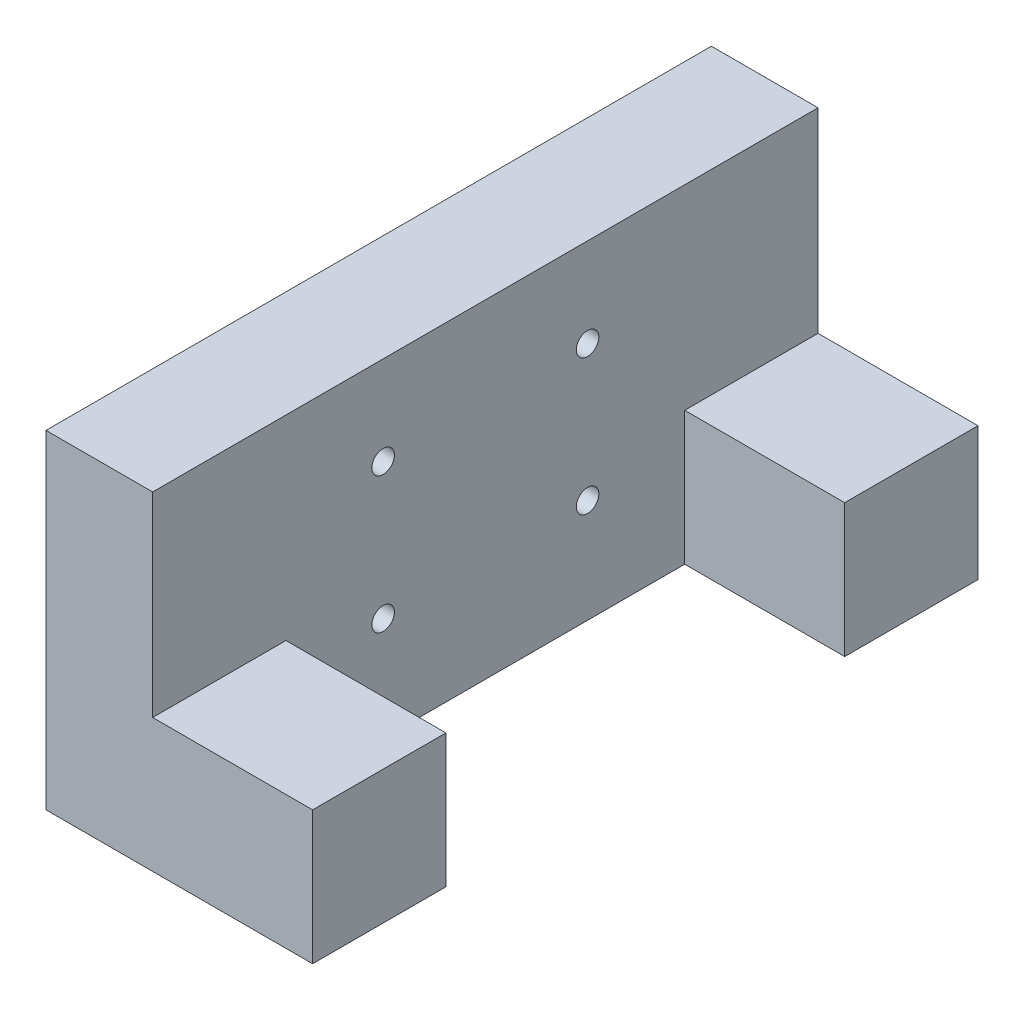
from build123d import *

# Parameters (mm, degrees)
SKETCH1_W           = 74.870479659
SKETCH1_H           = 36.98000569
BOSS_EXTRUDE1_DEPTH = 12
SKETCH4_W           = 15
SKETCH4_H           = 15
BOSS_EXTRUDE3_DEPTH = 18
SKETCH5_R           = 4.075
CUT_EXTRUDE1_DEPTH  = 12
SKETCH3_R           = 1.27
CUT_EXTRUDE3_DEPTH  = 13


with BuildPart() as part:
    # Sketch1 → Boss-Extrude1 (new body)
    with BuildSketch(Plane.ZY.offset(-35.076450848)):
        with Locations((-283.368991002, -85.966002845)):
            Rectangle(SKETCH1_W, SKETCH1_H)
    extrude(amount=BOSS_EXTRUDE1_DEPTH)

    # Sketch4 → Boss-Extrude3 (add)
    with BuildSketch(Plane(origin=(35.076450848, 0, 0), x_dir=(0, 0, -1), z_dir=(1, 0, 0))):
        with Locations((253.433751172, -96.95600569)):
            Rectangle(SKETCH4_W, SKETCH4_H)
        with Locations((313.304230831, -96.95600569)):
            Rectangle(SKETCH4_W, SKETCH4_H)
    extrude(amount=BOSS_EXTRUDE3_DEPTH)

    # Sketch5 → Cut-Extrude1 (cut)
    with BuildSketch(Plane.XZ.offset(104.45600569)):
        with Locations((46.026450848, -253.725)):
            Circle(SKETCH5_R)
        with Locations((46.026450848, -313.012982003)):
            Circle(SKETCH5_R)
    extrude(amount=-CUT_EXTRUDE1_DEPTH, mode=Mode.SUBTRACT)

    # Sketch3 → Cut-Extrude3 (cut, through all)
    with BuildSketch(Plane(origin=(35.076450848, 0, 0), x_dir=(0, 0, -1), z_dir=(1, 0, 0))):
        with Locations((271.868893694, -77.476)):
            Circle(SKETCH3_R)
        with Locations((271.868893694, -92.776)):
            Circle(SKETCH3_R)
        with Locations((294.868893694, -77.476)):
            Circle(SKETCH3_R)
        with Locations((294.868893694, -92.776)):
            Circle(SKETCH3_R)
    extrude(amount=-CUT_EXTRUDE3_DEPTH, mode=Mode.SUBTRACT)


solid = part.part
